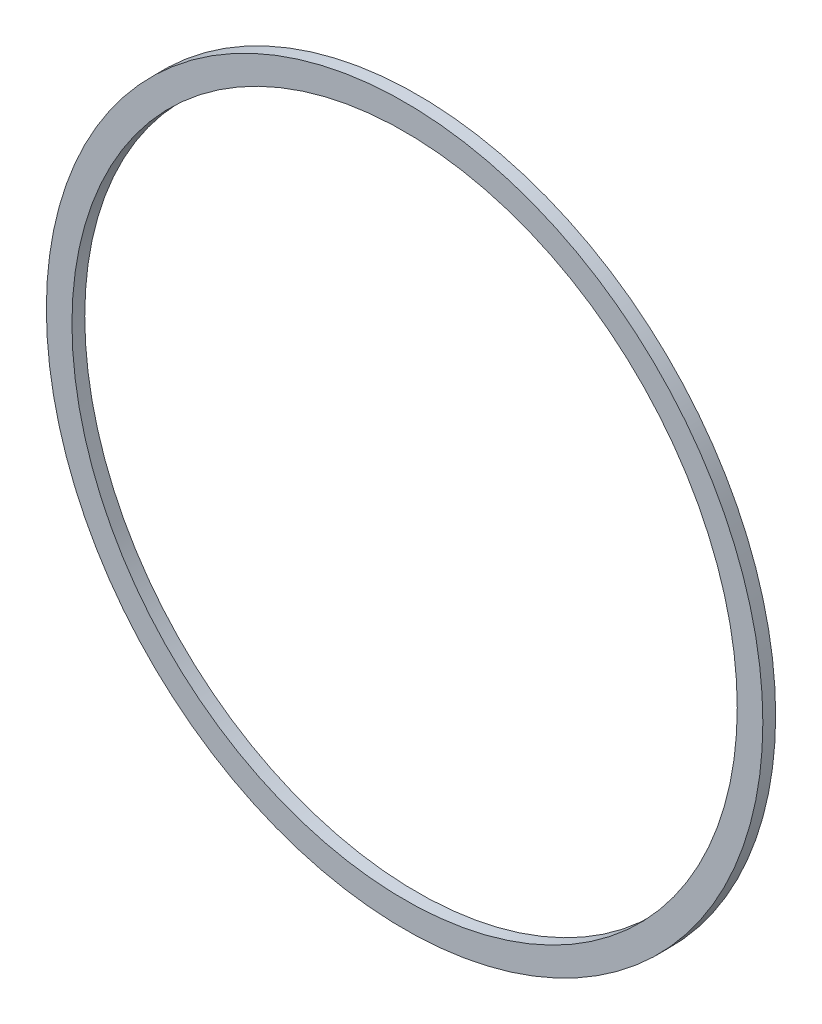
from build123d import *

# Parameters (mm, degrees)
SKETCH1_R           = 28
SKETCH1_R_2         = 26
BOSS_EXTRUDE1_DEPTH = 1


with BuildPart() as part:
    # Sketch1 → Boss-Extrude1 (new body)
    with BuildSketch(Plane.XY):
        Circle(SKETCH1_R)
        Circle(SKETCH1_R_2, mode=Mode.SUBTRACT)
    extrude(amount=BOSS_EXTRUDE1_DEPTH)


solid = part.part
